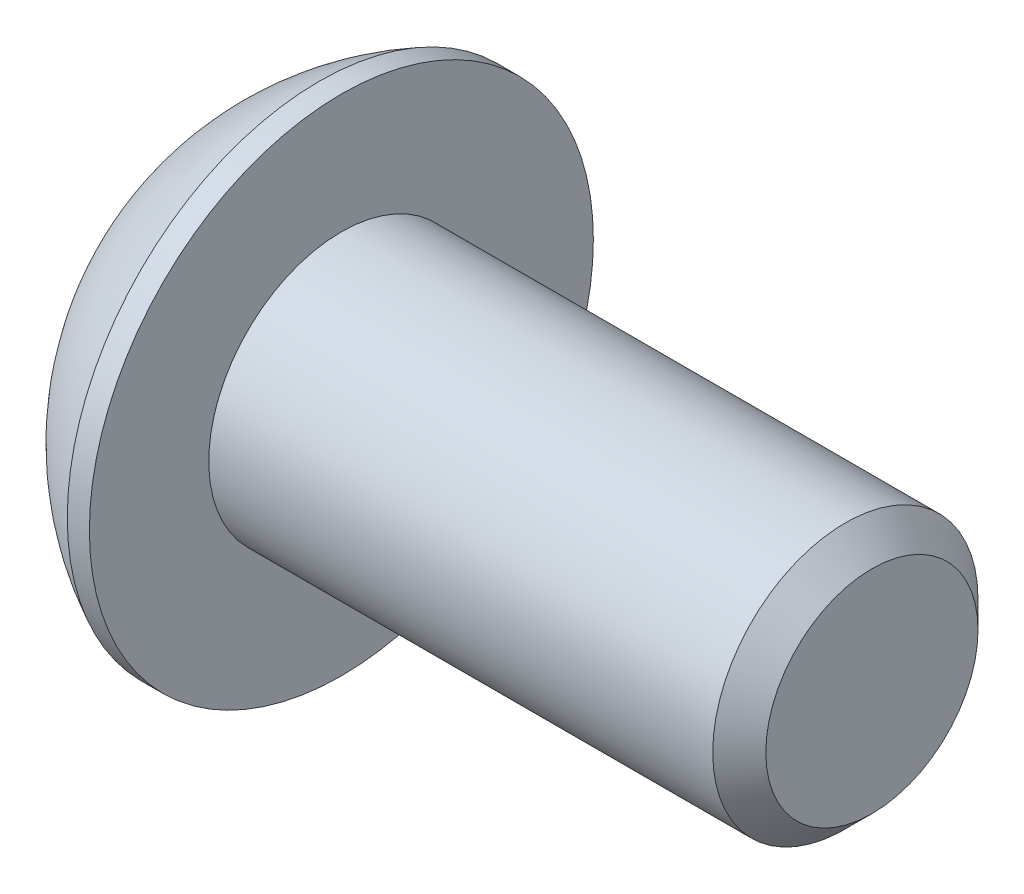
from build123d import *

# Parameters (mm, degrees)
SKETCH2_R           = 1.5
BOSS_EXTRUDE1_DEPTH = 6
CHAMFER1_SIZE       = 0.3
CUT_EXTRUDE1_DEPTH  = 1.2
SKETCH8_R           = 1.204700538
CUT_EXTRUDE2_DEPTH  = 1
CUT_EXTRUDE2_TAPER  = 45


with BuildPart() as part:
    # Sketch2 → Boss-Extrude1 (new body)
    with BuildSketch(Plane(origin=(0, 0, 0), x_dir=(0, 0, -1), z_dir=(1, 0, 0))):
        Circle(SKETCH2_R)
    extrude(amount=-BOSS_EXTRUDE1_DEPTH)

    # Chamfer1
    chamfer1_edges = [part.edges().sort_by_distance(p)[0] for p in [
        (0, 0, 1.5),
    ]]
    chamfer(chamfer1_edges, length=CHAMFER1_SIZE)

    # Sketch6 → Revolve1 (revolve)
    with BuildSketch(Plane.XY):
        with BuildLine():
            Line((-7.65, 0), (-7.65, 1.5))
            ThreePointArc((-7.65, 1.5), (-7.055944823, 2.284868705), (-6.25, 2.85))
            Line((-6.25, 2.85), (-6, 2.85))
            Line((-6, 2.85), (-6, 0))
            Line((-6, 0), (-7.65, 0))
        make_face()
    revolve(axis=Axis((-6, 0, 0), (-1, 0, 0)))

    # Sketch7 → Cut-Extrude1 (cut)
    with BuildSketch(Plane.ZY.offset(7.65)):
        Polygon((0, 1.154700538), (-1, 0.577350269), (-1, -0.577350269), (0, -1.154700538), (1, -0.577350269), (1, 0.577350269), align=None)
    extrude(amount=-CUT_EXTRUDE1_DEPTH, mode=Mode.SUBTRACT)

    # Sketch8 → Cut-Extrude2 (cut)
    with BuildSketch(Plane.ZY.offset(7.65)):
        Circle(SKETCH8_R)
    extrude(amount=-CUT_EXTRUDE2_DEPTH, taper=CUT_EXTRUDE2_TAPER, mode=Mode.SUBTRACT)


solid = part.part
